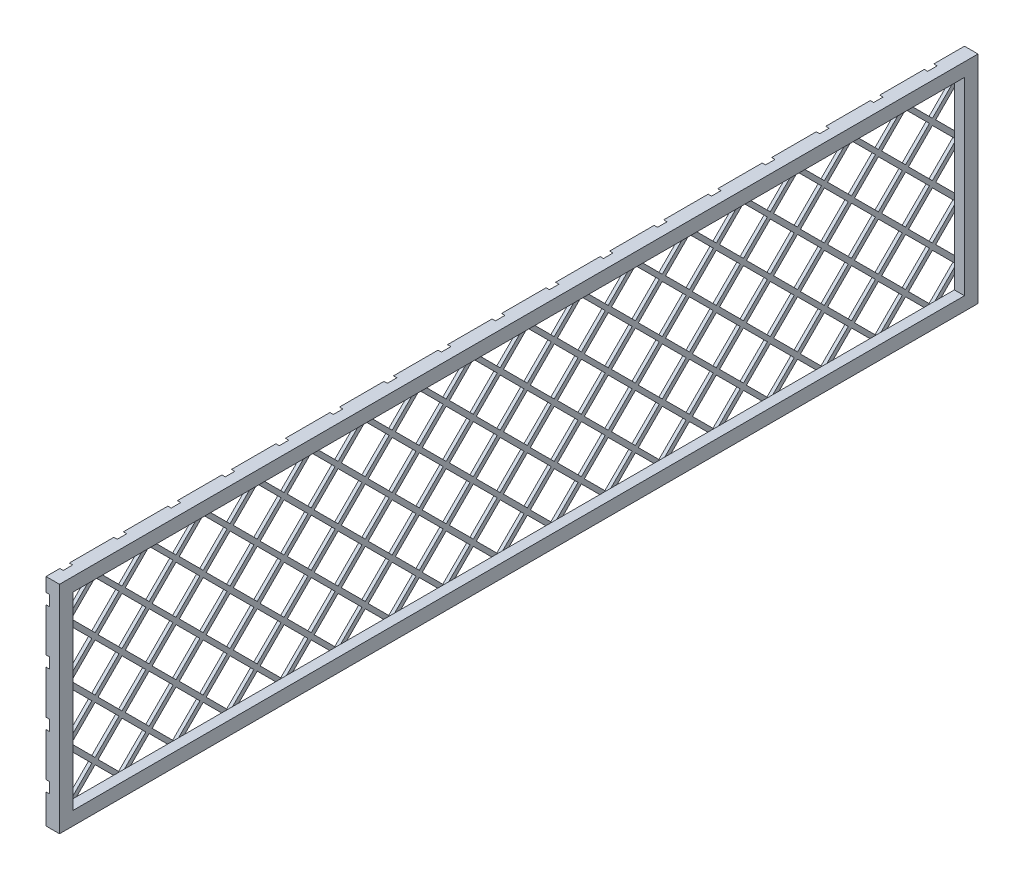
from build123d import *

# Parameters (mm, degrees)
SKETCH1_W           = 863.6
SKETCH1_H           = 203.2
SKETCH1_W_2         = 838.2
SKETCH1_H_2         = 177.8
BOSS_EXTRUDE1_DEPTH = 12.7
SKETCH2_W           = 838.2
SKETCH2_H           = 177.8
BOSS_EXTRUDE2_DEPTH = 3.175
CUT_EXTRUDE1_DEPTH  = 3.175


with BuildPart() as part:
    # Sketch1 → Boss-Extrude1 (new body)
    with BuildSketch(Plane(origin=(0, 0, 0), x_dir=(0, 0, -1), z_dir=(1, 0, 0))):
        with Locations((86.954561102, 122.846815835)):
            Rectangle(SKETCH1_W, SKETCH1_H)
        with Locations((86.954561102, 122.846815835)):
            Rectangle(SKETCH1_W_2, SKETCH1_H_2, mode=Mode.SUBTRACT)
    extrude(amount=BOSS_EXTRUDE1_DEPTH)

    # Sketch2 → Boss-Extrude2 (add)
    with BuildSketch(Plane.ZY):
        with Locations((-86.954561102, 122.846815835)):
            Rectangle(SKETCH2_W, SKETCH2_H)
    extrude(amount=-BOSS_EXTRUDE2_DEPTH)

    # Sketch3 → Cut-Extrude1 (cut)
    with BuildSketch(Plane(origin=(3.175, 0, 0), x_dir=(0, 0, -1), z_dir=(1, 0, 0))):
        Polygon((-324.286151071, 181.201261378), (-301.835510769, 203.651901681), (-279.384870466, 181.201261378), (-301.835510769, 158.750621075), align=None)
        Polygon((-276.579264344, 178.108148106), (-254.128624041, 155.657507803), (-276.579264344, 133.2068675), (-299.029904646, 155.657507803), align=None)
        Polygon((-327.379264344, 228.908148106), (-304.928624041, 206.457507803), (-327.379264344, 184.0068675), (-349.829904646, 206.457507803), align=None)
        Polygon((-276.579264344, 228.908148106), (-254.128624041, 206.457507803), (-276.579264344, 184.0068675), (-299.029904646, 206.457507803), align=None)
        Polygon((-251.035510769, 203.651901681), (-228.584870466, 181.201261378), (-251.035510769, 158.750621075), (-273.486151071, 181.201261378), align=None)
        Polygon((-203.328624041, 206.457507803), (-225.779264344, 184.0068675), (-248.229904646, 206.457507803), (-225.779264344, 228.908148106), align=None)
        Polygon((-200.235510769, 203.651901681), (-177.784870466, 181.201261378), (-200.235510769, 158.750621075), (-222.686151071, 181.201261378), align=None)
        Polygon((-152.528624041, 206.457507803), (-174.979264344, 184.0068675), (-197.429904646, 206.457507803), (-174.979264344, 228.908148106), align=None)
        Polygon((-149.435510769, 203.651901681), (-126.984870466, 181.201261378), (-149.435510769, 158.750621075), (-171.886151071, 181.201261378), align=None)
        Polygon((-101.728624041, 206.457507803), (-124.179264344, 184.0068675), (-146.629904646, 206.457507803), (-124.179264344, 228.908148106), align=None)
        Polygon((-98.635510769, 203.651901681), (-76.184870466, 181.201261378), (-98.635510769, 158.750621075), (-121.086151071, 181.201261378), align=None)
        Polygon((-50.928624041, 206.457507803), (-73.379264344, 184.0068675), (-95.829904646, 206.457507803), (-73.379264344, 228.908148106), align=None)
        Polygon((-47.835510769, 203.651901681), (-25.384870466, 181.201261378), (-47.835510769, 158.750621075), (-70.286151071, 181.201261378), align=None)
        Polygon((-0.128624041, 206.457507803), (-22.579264344, 184.0068675), (-45.029904646, 206.457507803), (-22.579264344, 228.908148106), align=None)
        Polygon((2.964489231, 203.651901681), (25.415129534, 181.201261378), (2.964489231, 158.750621075), (-19.486151071, 181.201261378), align=None)
        Polygon((50.671375959, 206.457507803), (28.220735656, 184.0068675), (5.770095354, 206.457507803), (28.220735656, 228.908148106), align=None)
        Polygon((53.764489231, 203.651901681), (76.215129534, 181.201261378), (53.764489231, 158.750621075), (31.313848929, 181.201261378), align=None)
        Polygon((101.471375959, 206.457507803), (79.020735656, 184.0068675), (56.570095354, 206.457507803), (79.020735656, 228.908148106), align=None)
        Polygon((104.564489231, 203.651901681), (127.015129534, 181.201261378), (104.564489231, 158.750621075), (82.113848929, 181.201261378), align=None)
        Polygon((152.271375959, 206.457507803), (129.820735656, 184.0068675), (107.370095354, 206.457507803), (129.820735656, 228.908148106), align=None)
        Polygon((155.364489231, 203.651901681), (177.815129534, 181.201261378), (155.364489231, 158.750621075), (132.913848929, 181.201261378), align=None)
        Polygon((203.071375959, 206.457507803), (180.620735656, 184.0068675), (158.170095354, 206.457507803), (180.620735656, 228.908148106), align=None)
        Polygon((206.164489231, 203.651901681), (228.615129534, 181.201261378), (206.164489231, 158.750621075), (183.713848929, 181.201261378), align=None)
        Polygon((253.871375959, 206.457507803), (231.420735656, 184.0068675), (208.970095354, 206.457507803), (231.420735656, 228.908148106), align=None)
        Polygon((256.964489231, 203.651901681), (279.415129534, 181.201261378), (256.964489231, 158.750621075), (234.513848929, 181.201261378), align=None)
        Polygon((304.671375959, 206.457507803), (282.220735656, 184.0068675), (259.770095354, 206.457507803), (282.220735656, 228.908148106), align=None)
        Polygon((307.764489231, 203.651901681), (330.215129534, 181.201261378), (307.764489231, 158.750621075), (285.313848929, 181.201261378), align=None)
        Polygon((355.471375959, 206.457507803), (333.020735656, 184.0068675), (310.570095354, 206.457507803), (333.020735656, 228.908148106), align=None)
        Polygon((358.564489231, 203.651901681), (381.015129534, 181.201261378), (358.564489231, 158.750621075), (336.113848929, 181.201261378), align=None)
        Polygon((406.271375959, 206.457507803), (383.820735656, 184.0068675), (361.370095354, 206.457507803), (383.820735656, 228.908148106), align=None)
        Polygon((409.364489231, 203.651901681), (431.815129534, 181.201261378), (409.364489231, 158.750621075), (386.913848929, 181.201261378), align=None)
        Polygon((457.071375959, 206.457507803), (434.620735656, 184.0068675), (412.170095354, 206.457507803), (434.620735656, 228.908148106), align=None)
        Polygon((460.164489231, 203.651901681), (482.615129534, 181.201261378), (460.164489231, 158.750621075), (437.713848929, 181.201261378), align=None)
        Polygon((507.871375959, 206.457507803), (485.420735656, 184.0068675), (462.970095354, 206.457507803), (485.420735656, 228.908148106), align=None)
        Polygon((510.964489231, 203.651901681), (533.415129534, 181.201261378), (510.964489231, 158.750621075), (488.513848929, 181.201261378), align=None)
        Polygon((-251.035510769, 152.851901681), (-228.584870466, 130.401261378), (-251.035510769, 107.950621075), (-273.486151071, 130.401261378), align=None)
        Polygon((-203.328624041, 155.657507803), (-225.779264344, 133.2068675), (-248.229904646, 155.657507803), (-225.779264344, 178.108148106), align=None)
        Polygon((-200.235510769, 152.851901681), (-177.784870466, 130.401261378), (-200.235510769, 107.950621075), (-222.686151071, 130.401261378), align=None)
        Polygon((-152.528624041, 155.657507803), (-174.979264344, 133.2068675), (-197.429904646, 155.657507803), (-174.979264344, 178.108148106), align=None)
        Polygon((-149.435510769, 152.851901681), (-126.984870466, 130.401261378), (-149.435510769, 107.950621075), (-171.886151071, 130.401261378), align=None)
        Polygon((-101.728624041, 155.657507803), (-124.179264344, 133.2068675), (-146.629904646, 155.657507803), (-124.179264344, 178.108148106), align=None)
        Polygon((-98.635510769, 152.851901681), (-76.184870466, 130.401261378), (-98.635510769, 107.950621075), (-121.086151071, 130.401261378), align=None)
        Polygon((-50.928624041, 155.657507803), (-73.379264344, 133.2068675), (-95.829904646, 155.657507803), (-73.379264344, 178.108148106), align=None)
        Polygon((-47.835510769, 152.851901681), (-25.384870466, 130.401261378), (-47.835510769, 107.950621075), (-70.286151071, 130.401261378), align=None)
        Polygon((-0.128624041, 155.657507803), (-22.579264344, 133.2068675), (-45.029904646, 155.657507803), (-22.579264344, 178.108148106), align=None)
        Polygon((2.964489231, 152.851901681), (25.415129534, 130.401261378), (2.964489231, 107.950621075), (-19.486151071, 130.401261378), align=None)
        Polygon((50.671375959, 155.657507803), (28.220735656, 133.2068675), (5.770095354, 155.657507803), (28.220735656, 178.108148106), align=None)
        Polygon((53.764489231, 152.851901681), (76.215129534, 130.401261378), (53.764489231, 107.950621075), (31.313848929, 130.401261378), align=None)
        Polygon((101.471375959, 155.657507803), (79.020735656, 133.2068675), (56.570095354, 155.657507803), (79.020735656, 178.108148106), align=None)
        Polygon((104.564489231, 152.851901681), (127.015129534, 130.401261378), (104.564489231, 107.950621075), (82.113848929, 130.401261378), align=None)
        Polygon((152.271375959, 155.657507803), (129.820735656, 133.2068675), (107.370095354, 155.657507803), (129.820735656, 178.108148106), align=None)
        Polygon((155.364489231, 152.851901681), (177.815129534, 130.401261378), (155.364489231, 107.950621075), (132.913848929, 130.401261378), align=None)
        Polygon((203.071375959, 155.657507803), (180.620735656, 133.2068675), (158.170095354, 155.657507803), (180.620735656, 178.108148106), align=None)
        Polygon((206.164489231, 152.851901681), (228.615129534, 130.401261378), (206.164489231, 107.950621075), (183.713848929, 130.401261378), align=None)
        Polygon((253.871375959, 155.657507803), (231.420735656, 133.2068675), (208.970095354, 155.657507803), (231.420735656, 178.108148106), align=None)
        Polygon((256.964489231, 152.851901681), (279.415129534, 130.401261378), (256.964489231, 107.950621075), (234.513848929, 130.401261378), align=None)
        Polygon((304.671375959, 155.657507803), (282.220735656, 133.2068675), (259.770095354, 155.657507803), (282.220735656, 178.108148106), align=None)
        Polygon((307.764489231, 152.851901681), (330.215129534, 130.401261378), (307.764489231, 107.950621075), (285.313848929, 130.401261378), align=None)
        Polygon((355.471375959, 155.657507803), (333.020735656, 133.2068675), (310.570095354, 155.657507803), (333.020735656, 178.108148106), align=None)
        Polygon((358.564489231, 152.851901681), (381.015129534, 130.401261378), (358.564489231, 107.950621075), (336.113848929, 130.401261378), align=None)
        Polygon((406.271375959, 155.657507803), (383.820735656, 133.2068675), (361.370095354, 155.657507803), (383.820735656, 178.108148106), align=None)
        Polygon((409.364489231, 152.851901681), (431.815129534, 130.401261378), (409.364489231, 107.950621075), (386.913848929, 130.401261378), align=None)
        Polygon((457.071375959, 155.657507803), (434.620735656, 133.2068675), (412.170095354, 155.657507803), (434.620735656, 178.108148106), align=None)
        Polygon((460.164489231, 152.851901681), (482.615129534, 130.401261378), (460.164489231, 107.950621075), (437.713848929, 130.401261378), align=None)
        Polygon((507.871375959, 155.657507803), (485.420735656, 133.2068675), (462.970095354, 155.657507803), (485.420735656, 178.108148106), align=None)
        Polygon((510.964489231, 152.851901681), (533.415129534, 130.401261378), (510.964489231, 107.950621075), (488.513848929, 130.401261378), align=None)
        Polygon((-254.128624041, 104.857507803), (-276.579264344, 82.4068675), (-299.029904646, 104.857507803), (-276.579264344, 127.308148106), align=None)
        Polygon((-251.035510769, 102.051901681), (-228.584870466, 79.601261378), (-251.035510769, 57.150621075), (-273.486151071, 79.601261378), align=None)
        Polygon((-203.328624041, 104.857507803), (-225.779264344, 82.4068675), (-248.229904646, 104.857507803), (-225.779264344, 127.308148106), align=None)
        Polygon((-200.235510769, 102.051901681), (-177.784870466, 79.601261378), (-200.235510769, 57.150621075), (-222.686151071, 79.601261378), align=None)
        Polygon((-152.528624041, 104.857507803), (-174.979264344, 82.4068675), (-197.429904646, 104.857507803), (-174.979264344, 127.308148106), align=None)
        Polygon((-149.435510769, 102.051901681), (-126.984870466, 79.601261378), (-149.435510769, 57.150621075), (-171.886151071, 79.601261378), align=None)
        Polygon((-101.728624041, 104.857507803), (-124.179264344, 82.4068675), (-146.629904646, 104.857507803), (-124.179264344, 127.308148106), align=None)
        Polygon((-98.635510769, 102.051901681), (-76.184870466, 79.601261378), (-98.635510769, 57.150621075), (-121.086151071, 79.601261378), align=None)
        Polygon((-50.928624041, 104.857507803), (-73.379264344, 82.4068675), (-95.829904646, 104.857507803), (-73.379264344, 127.308148106), align=None)
        Polygon((-47.835510769, 102.051901681), (-25.384870466, 79.601261378), (-47.835510769, 57.150621075), (-70.286151071, 79.601261378), align=None)
        Polygon((-0.128624041, 104.857507803), (-22.579264344, 82.4068675), (-45.029904646, 104.857507803), (-22.579264344, 127.308148106), align=None)
        Polygon((2.964489231, 102.051901681), (25.415129534, 79.601261378), (2.964489231, 57.150621075), (-19.486151071, 79.601261378), align=None)
        Polygon((50.671375959, 104.857507803), (28.220735656, 82.4068675), (5.770095354, 104.857507803), (28.220735656, 127.308148106), align=None)
        Polygon((53.764489231, 102.051901681), (76.215129534, 79.601261378), (53.764489231, 57.150621075), (31.313848929, 79.601261378), align=None)
        Polygon((101.471375959, 104.857507803), (79.020735656, 82.4068675), (56.570095354, 104.857507803), (79.020735656, 127.308148106), align=None)
        Polygon((104.564489231, 102.051901681), (127.015129534, 79.601261378), (104.564489231, 57.150621075), (82.113848929, 79.601261378), align=None)
        Polygon((152.271375959, 104.857507803), (129.820735656, 82.4068675), (107.370095354, 104.857507803), (129.820735656, 127.308148106), align=None)
        Polygon((155.364489231, 102.051901681), (177.815129534, 79.601261378), (155.364489231, 57.150621075), (132.913848929, 79.601261378), align=None)
        Polygon((203.071375959, 104.857507803), (180.620735656, 82.4068675), (158.170095354, 104.857507803), (180.620735656, 127.308148106), align=None)
        Polygon((206.164489231, 102.051901681), (228.615129534, 79.601261378), (206.164489231, 57.150621075), (183.713848929, 79.601261378), align=None)
        Polygon((253.871375959, 104.857507803), (231.420735656, 82.4068675), (208.970095354, 104.857507803), (231.420735656, 127.308148106), align=None)
        Polygon((256.964489231, 102.051901681), (279.415129534, 79.601261378), (256.964489231, 57.150621075), (234.513848929, 79.601261378), align=None)
        Polygon((304.671375959, 104.857507803), (282.220735656, 82.4068675), (259.770095354, 104.857507803), (282.220735656, 127.308148106), align=None)
        Polygon((307.764489231, 102.051901681), (330.215129534, 79.601261378), (307.764489231, 57.150621075), (285.313848929, 79.601261378), align=None)
        Polygon((355.471375959, 104.857507803), (333.020735656, 82.4068675), (310.570095354, 104.857507803), (333.020735656, 127.308148106), align=None)
        Polygon((358.564489231, 102.051901681), (381.015129534, 79.601261378), (358.564489231, 57.150621075), (336.113848929, 79.601261378), align=None)
        Polygon((406.271375959, 104.857507803), (383.820735656, 82.4068675), (361.370095354, 104.857507803), (383.820735656, 127.308148106), align=None)
        Polygon((409.364489231, 102.051901681), (431.815129534, 79.601261378), (409.364489231, 57.150621075), (386.913848929, 79.601261378), align=None)
        Polygon((457.071375959, 104.857507803), (434.620735656, 82.4068675), (412.170095354, 104.857507803), (434.620735656, 127.308148106), align=None)
        Polygon((460.164489231, 102.051901681), (482.615129534, 79.601261378), (460.164489231, 57.150621075), (437.713848929, 79.601261378), align=None)
        Polygon((507.871375959, 104.857507803), (485.420735656, 82.4068675), (462.970095354, 104.857507803), (485.420735656, 127.308148106), align=None)
        Polygon((510.964489231, 102.051901681), (533.415129534, 79.601261378), (510.964489231, 57.150621075), (488.513848929, 79.601261378), align=None)
        Polygon((-254.128624041, 54.057507803), (-276.579264344, 31.6068675), (-299.029904646, 54.057507803), (-276.579264344, 76.508148106), align=None)
        Polygon((-251.035510769, 51.251901681), (-228.584870466, 28.801261378), (-251.035510769, 6.350621075), (-273.486151071, 28.801261378), align=None)
        Polygon((-203.328624041, 54.057507803), (-225.779264344, 31.6068675), (-248.229904646, 54.057507803), (-225.779264344, 76.508148106), align=None)
        Polygon((-200.235510769, 51.251901681), (-177.784870466, 28.801261378), (-200.235510769, 6.350621075), (-222.686151071, 28.801261378), align=None)
        Polygon((-152.528624041, 54.057507803), (-174.979264344, 31.6068675), (-197.429904646, 54.057507803), (-174.979264344, 76.508148106), align=None)
        Polygon((-149.435510769, 51.251901681), (-126.984870466, 28.801261378), (-149.435510769, 6.350621075), (-171.886151071, 28.801261378), align=None)
        Polygon((-101.728624041, 54.057507803), (-124.179264344, 31.6068675), (-146.629904646, 54.057507803), (-124.179264344, 76.508148106), align=None)
        Polygon((-98.635510769, 51.251901681), (-76.184870466, 28.801261378), (-98.635510769, 6.350621075), (-121.086151071, 28.801261378), align=None)
        Polygon((-50.928624041, 54.057507803), (-73.379264344, 31.6068675), (-95.829904646, 54.057507803), (-73.379264344, 76.508148106), align=None)
        Polygon((-47.835510769, 51.251901681), (-25.384870466, 28.801261378), (-47.835510769, 6.350621075), (-70.286151071, 28.801261378), align=None)
        Polygon((-0.128624041, 54.057507803), (-22.579264344, 31.6068675), (-45.029904646, 54.057507803), (-22.579264344, 76.508148106), align=None)
        Polygon((2.964489231, 51.251901681), (25.415129534, 28.801261378), (2.964489231, 6.350621075), (-19.486151071, 28.801261378), align=None)
        Polygon((50.671375959, 54.057507803), (28.220735656, 31.6068675), (5.770095354, 54.057507803), (28.220735656, 76.508148106), align=None)
        Polygon((53.764489231, 51.251901681), (76.215129534, 28.801261378), (53.764489231, 6.350621075), (31.313848929, 28.801261378), align=None)
        Polygon((101.471375959, 54.057507803), (79.020735656, 31.6068675), (56.570095354, 54.057507803), (79.020735656, 76.508148106), align=None)
        Polygon((104.564489231, 51.251901681), (127.015129534, 28.801261378), (104.564489231, 6.350621075), (82.113848929, 28.801261378), align=None)
        Polygon((152.271375959, 54.057507803), (129.820735656, 31.6068675), (107.370095354, 54.057507803), (129.820735656, 76.508148106), align=None)
        Polygon((155.364489231, 51.251901681), (177.815129534, 28.801261378), (155.364489231, 6.350621075), (132.913848929, 28.801261378), align=None)
        Polygon((203.071375959, 54.057507803), (180.620735656, 31.6068675), (158.170095354, 54.057507803), (180.620735656, 76.508148106), align=None)
        Polygon((206.164489231, 51.251901681), (228.615129534, 28.801261378), (206.164489231, 6.350621075), (183.713848929, 28.801261378), align=None)
        Polygon((253.871375959, 54.057507803), (231.420735656, 31.6068675), (208.970095354, 54.057507803), (231.420735656, 76.508148106), align=None)
        Polygon((256.964489231, 51.251901681), (279.415129534, 28.801261378), (256.964489231, 6.350621075), (234.513848929, 28.801261378), align=None)
        Polygon((304.671375959, 54.057507803), (282.220735656, 31.6068675), (259.770095354, 54.057507803), (282.220735656, 76.508148106), align=None)
        Polygon((307.764489231, 51.251901681), (330.215129534, 28.801261378), (307.764489231, 6.350621075), (285.313848929, 28.801261378), align=None)
        Polygon((355.471375959, 54.057507803), (333.020735656, 31.6068675), (310.570095354, 54.057507803), (333.020735656, 76.508148106), align=None)
        Polygon((358.564489231, 51.251901681), (381.015129534, 28.801261378), (358.564489231, 6.350621075), (336.113848929, 28.801261378), align=None)
        Polygon((406.271375959, 54.057507803), (383.820735656, 31.6068675), (361.370095354, 54.057507803), (383.820735656, 76.508148106), align=None)
        Polygon((409.364489231, 51.251901681), (431.815129534, 28.801261378), (409.364489231, 6.350621075), (386.913848929, 28.801261378), align=None)
        Polygon((457.071375959, 54.057507803), (434.620735656, 31.6068675), (412.170095354, 54.057507803), (434.620735656, 76.508148106), align=None)
        Polygon((460.164489231, 51.251901681), (482.615129534, 28.801261378), (460.164489231, 6.350621075), (437.713848929, 28.801261378), align=None)
        Polygon((507.871375959, 54.057507803), (485.420735656, 31.6068675), (462.970095354, 54.057507803), (485.420735656, 76.508148106), align=None)
        Polygon((510.964489231, 51.251901681), (533.415129534, 28.801261378), (510.964489231, 6.350621075), (488.513848929, 28.801261378), align=None)
        Polygon((-304.928624041, 155.657507803), (-327.379264344, 133.2068675), (-349.829904646, 155.657507803), (-327.379264344, 178.108148106), align=None)
        Polygon((-301.835510769, 152.851901681), (-279.384870466, 130.401261378), (-301.835510769, 107.950621075), (-324.286151071, 130.401261378), align=None)
        Polygon((-304.928624041, 104.857507803), (-327.379264344, 82.4068675), (-349.829904646, 104.857507803), (-327.379264344, 127.308148106), align=None)
        Polygon((-301.835510769, 102.051901681), (-279.384870466, 79.601261378), (-301.835510769, 57.150621075), (-324.286151071, 79.601261378), align=None)
        Polygon((-304.928624041, 54.057507803), (-327.379264344, 31.6068675), (-349.829904646, 54.057507803), (-327.379264344, 76.508148106), align=None)
        Polygon((-301.835510769, 51.251901681), (-279.384870466, 28.801261378), (-301.835510769, 6.350621075), (-324.286151071, 28.801261378), align=None)
    extrude(amount=-CUT_EXTRUDE1_DEPTH, mode=Mode.SUBTRACT)


solid = part.part
